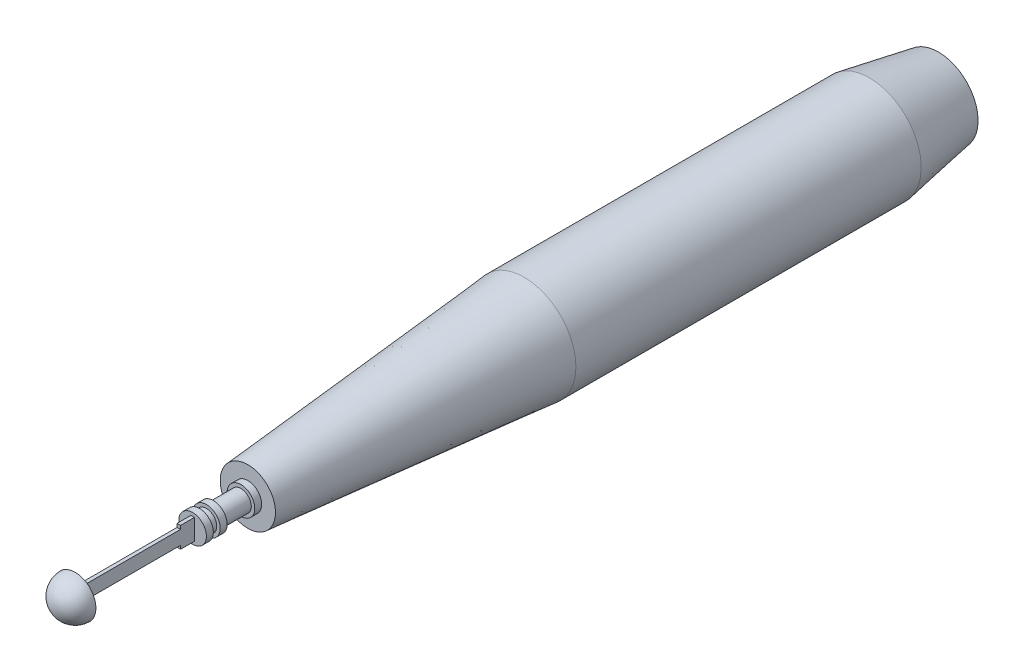
from build123d import *

# Parameters (mm, degrees)
SKETCH1_R            = 7.5
BOSS_EXTRUDE1_DEPTH  = 25
SKETCH4_R            = 7.5
BOSS_EXTRUDE4_DEPTH  = 40
BOSS_EXTRUDE4_TAPER  = 5
SKETCH5_R            = 2
BOSS_EXTRUDE5_DEPTH  = 1
SKETCH5_5_R          = 1.5
BOSS_EXTRUDE6_DEPTH  = 5
SKETCH6_R            = 2
BOSS_EXTRUDE7_DEPTH  = 1
SKETCH8_R            = 1.5
BOSS_EXTRUDE8_DEPTH  = 1
SKETCH9_R            = 2
BOSS_EXTRUDE9_DEPTH  = 1
SKETCH10_W           = 0.5
SKETCH10_H           = 3
BOSS_EXTRUDE10_DEPTH = 2
SKETCH11_W           = 0.5
SKETCH11_H           = 2
BOSS_EXTRUDE11_DEPTH = 15
SKETCH14_R           = 7.5
BOSS_EXTRUDE13_DEPTH = 10
BOSS_EXTRUDE13_TAPER = 10
SCALE1_SCALE         = 1.6


with BuildPart() as part:
    # Sketch1 → Boss-Extrude1 (new, symmetric)
    with BuildSketch(Plane.XY):
        Circle(SKETCH1_R)
    extrude(amount=BOSS_EXTRUDE1_DEPTH, both=True)

    # Sketch4 → Boss-Extrude4 (add)
    with BuildSketch(Plane.XY.offset(25)):
        Circle(SKETCH4_R)
    extrude(amount=BOSS_EXTRUDE4_DEPTH, taper=BOSS_EXTRUDE4_TAPER)

    # Sketch5 → Boss-Extrude5 (add)
    with BuildSketch(Plane.XY.offset(65)):
        Circle(SKETCH5_R)
    extrude(amount=BOSS_EXTRUDE5_DEPTH)

    # Sketch5_5 → Boss-Extrude6 (add)
    with BuildSketch(Plane.XY.offset(65)):
        Circle(SKETCH5_5_R)
    extrude(amount=BOSS_EXTRUDE6_DEPTH)

    # Sketch6 → Boss-Extrude7 (add)
    with BuildSketch(Plane.XY.offset(70)):
        Circle(SKETCH6_R)
    extrude(amount=BOSS_EXTRUDE7_DEPTH)

    # Sketch8 → Boss-Extrude8 (add)
    with BuildSketch(Plane.XY.offset(71)):
        Circle(SKETCH8_R)
    extrude(amount=BOSS_EXTRUDE8_DEPTH)

    # Sketch9 → Boss-Extrude9 (add)
    with BuildSketch(Plane.XY.offset(72)):
        Circle(SKETCH9_R)
    extrude(amount=BOSS_EXTRUDE9_DEPTH)

    # Sketch10 → Boss-Extrude10 (add)
    with BuildSketch(Plane.XY.offset(73)):
        Rectangle(SKETCH10_W, SKETCH10_H)
    extrude(amount=BOSS_EXTRUDE10_DEPTH)

    # Sketch11 → Boss-Extrude11 (add)
    with BuildSketch(Plane.XY.offset(75)):
        Rectangle(SKETCH11_W, SKETCH11_H)
    extrude(amount=BOSS_EXTRUDE11_DEPTH)

    # Sketch12 → Revolve1 (revolve)
    with BuildSketch(Plane(origin=(0, 0, 0), x_dir=(0, 0, -1), z_dir=(1, 0, 0))):
        with BuildLine():
            Line((-90, 0), (-93, 0))
            ThreePointArc((-93, 0), (-92.121320344, 2.121320344), (-90, 3))
            Line((-90, 3), (-90, 0))
        make_face()
    revolve(axis=Axis((0, 0, 90), (0, 0, 1)))

    # Sketch14 → Boss-Extrude13 (add)
    with BuildSketch(Plane(origin=(0, 0, -25), x_dir=(-1, 0, 0), z_dir=(0, 0, -1))):
        Circle(SKETCH14_R)
    extrude(amount=BOSS_EXTRUDE13_DEPTH, taper=BOSS_EXTRUDE13_TAPER)


with BuildPart() as part_1:
    # Scale1: scaled about (0, 0, 10.008668497)
    add(part.part.scale(SCALE1_SCALE).moved(Location((0, 0, -6.005201098))))


solid = part_1.part
